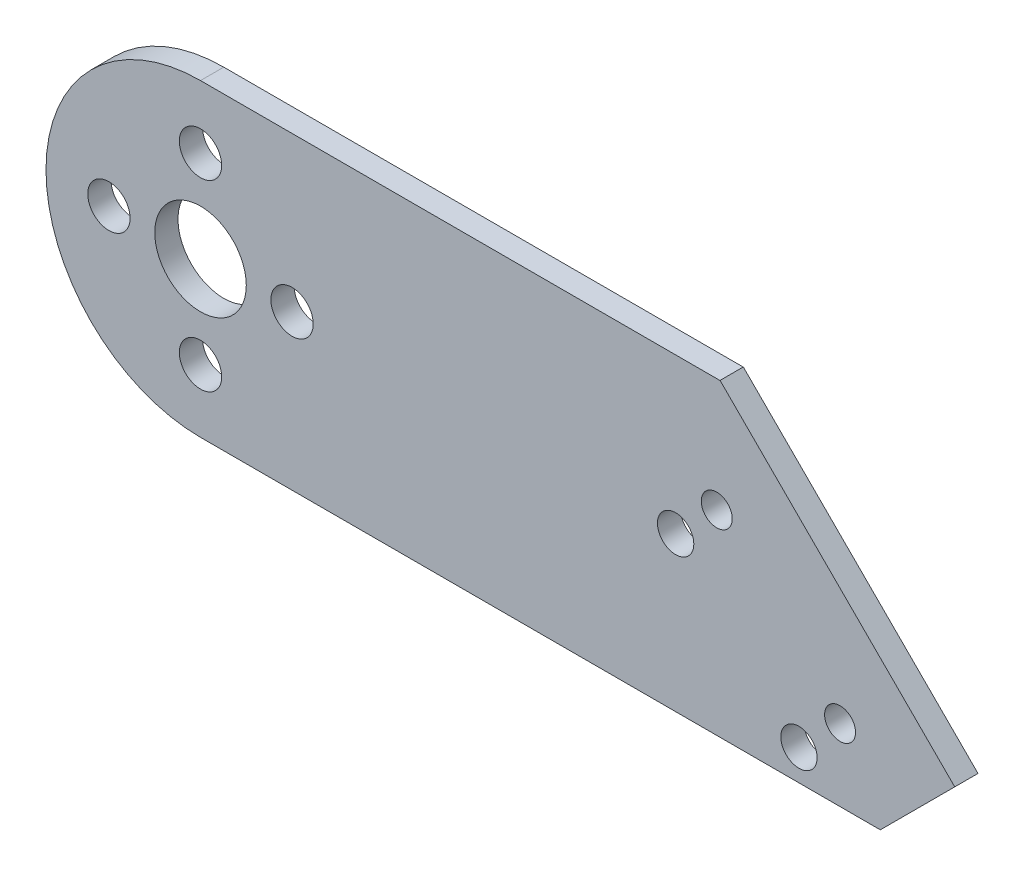
from build123d import *

# Parameters (mm, degrees)
SKETCH2_R           = 1.85
SKETCH2_R_2         = 1.35255
SKETCH2_R_3         = 4
SKETCH2_R_4         = 1.5875
BOSS_EXTRUDE1_DEPTH = 2.032


with BuildPart() as part:
    # Sketch2 → Boss-Extrude1 (new body)
    with BuildSketch(Plane.XY):
        with BuildLine():
            Line((45.396235039, 13.510064828), (45.386170211, 13.5))
            Line((45.386170211, 13.5), (0, 13.5))
            ThreePointArc((0, 13.5), (-13.5, 0), (0, -13.5))
            Line((0, -13.5), (59.39836352, -13.5))
            Line((59.39836352, -13.5), (65.902331694, -6.996031827))
            Line((65.902331694, -6.996031827), (45.396235039, 13.510064828))
        make_face()
        with Locations((8, 0)):
            Circle(SKETCH2_R, mode=Mode.SUBTRACT)
        with Locations((55.883335711, -7.214527822)):
            Circle(SKETCH2_R_2, mode=Mode.SUBTRACT)
        with Locations((45.107028366, 3.561779523)):
            Circle(SKETCH2_R_2, mode=Mode.SUBTRACT)
        Circle(SKETCH2_R_3, mode=Mode.SUBTRACT)
        with Locations((0, -8)):
            Circle(SKETCH2_R, mode=Mode.SUBTRACT)
        with Locations((-8, 0)):
            Circle(SKETCH2_R, mode=Mode.SUBTRACT)
        with Locations((0, 8)):
            Circle(SKETCH2_R, mode=Mode.SUBTRACT)
        with Locations((41.514925917, -0.030322925)):
            Circle(SKETCH2_R_4, mode=Mode.SUBTRACT)
        with Locations((52.291233263, -10.80663027)):
            Circle(SKETCH2_R_4, mode=Mode.SUBTRACT)
    extrude(amount=BOSS_EXTRUDE1_DEPTH)


solid = part.part
